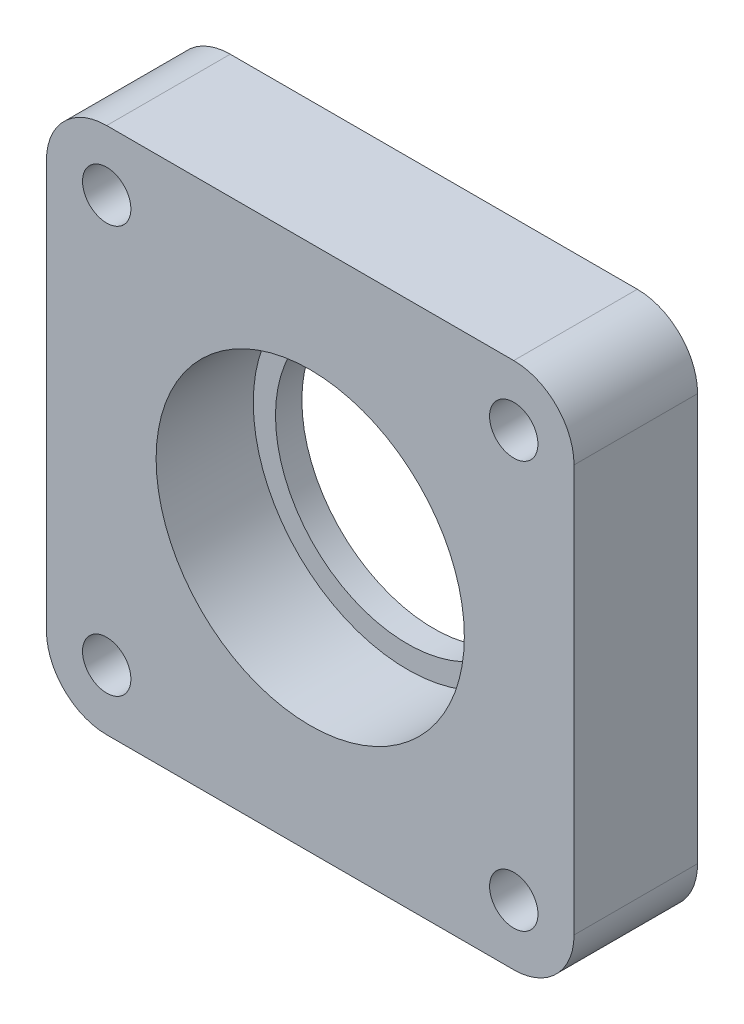
from build123d import *

# Parameters (mm, degrees)
CROQUIS1_R              = 2.75
CROQUIS1_R_2            = 17.525
SALIENTE_EXTRUIR1_DEPTH = 14.05
CROQUIS3_R              = 20
CROQUIS3_R_2            = 15
SALIENTE_EXTRUIR2_DEPTH = 3


with BuildPart() as part:
    # Croquis1 → Saliente-Extruir1 (new body)
    with BuildSketch(Plane.XY):
        with BuildLine():
            Line((-99.001786664, 30.959159172), (-145.291786664, 30.959159172))
            ThreePointArc((-145.291786664, 30.959159172), (-150.139003649, 28.951376157), (-152.146786664, 24.104159172))
            Line((-152.146786664, 24.104159172), (-152.146786664, -22.185840828))
            ThreePointArc((-152.146786664, -22.185840828), (-150.139003649, -27.033057813), (-145.291786664, -29.040840828))
            Line((-145.291786664, -29.040840828), (-99.001786664, -29.040840828))
            ThreePointArc((-99.001786664, -29.040840828), (-94.154569679, -27.033057813), (-92.146786664, -22.185840828))
            Line((-92.146786664, -22.185840828), (-92.146786664, 24.104159172))
            ThreePointArc((-92.146786664, 24.104159172), (-94.154569679, 28.951376157), (-99.001786664, 30.959159172))
        make_face()
        with Locations((-145.291786664, 24.104159172)):
            Circle(CROQUIS1_R, mode=Mode.SUBTRACT)
        with Locations((-145.291786664, -22.185840828)):
            Circle(CROQUIS1_R, mode=Mode.SUBTRACT)
        with Locations((-99.001786664, -22.185840828)):
            Circle(CROQUIS1_R, mode=Mode.SUBTRACT)
        with Locations((-99.001786664, 24.104159172)):
            Circle(CROQUIS1_R, mode=Mode.SUBTRACT)
        with Locations((-122.146786664, 0.959159172)):
            Circle(CROQUIS1_R_2, mode=Mode.SUBTRACT)
    extrude(amount=SALIENTE_EXTRUIR1_DEPTH)

    # Croquis3 → Saliente-Extruir2 (add)
    with BuildSketch(Plane(origin=(0, 0, 0), x_dir=(-1, 0, 0), z_dir=(0, 0, -1))):
        with Locations((122.146786664, 0.959159172)):
            Circle(CROQUIS3_R)
        with Locations((122.146786664, 0.959159172)):
            Circle(CROQUIS3_R_2, mode=Mode.SUBTRACT)
    extrude(amount=-SALIENTE_EXTRUIR2_DEPTH)


solid = part.part
